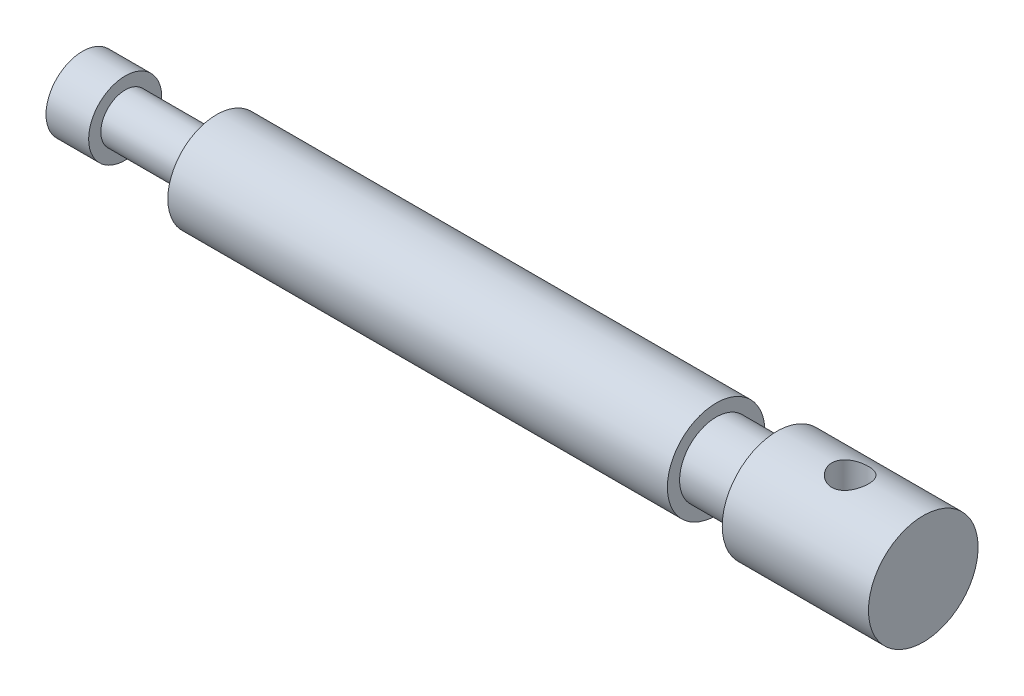
from build123d import *

# Parameters (mm, degrees)
CUT_EXTRUDE3_DEPTH      = 10
CUT_EXTRUDE3_DEPTH_BACK = 10
SKETCH2_R               = 3


with BuildPart() as part:
    # Sketch1 → Revolve1 (revolve)
    with BuildSketch(Plane.XY):
        Polygon((0, 6), (0, 0), (138, 0), (138, 9), (114, 9), (114, 6), (104, 6), (104, 8), (22, 8), (22, 4), (7, 4), (7, 6), align=None)
    revolve(axis=Axis((0, 0, 0), (1, 0, 0)))

    # Sketch2 → Cut-Extrude3 (cut, two sides: drawn at the far end of the back side and taken through both)
    with BuildSketch(Plane(origin=(0, 0, 0), x_dir=(1, 0, 0), z_dir=(0, 1, 0)).offset(-CUT_EXTRUDE3_DEPTH_BACK)):
        with Locations((126, 0)):
            Circle(SKETCH2_R)
    extrude(amount=CUT_EXTRUDE3_DEPTH + CUT_EXTRUDE3_DEPTH_BACK, mode=Mode.SUBTRACT)


solid = part.part
